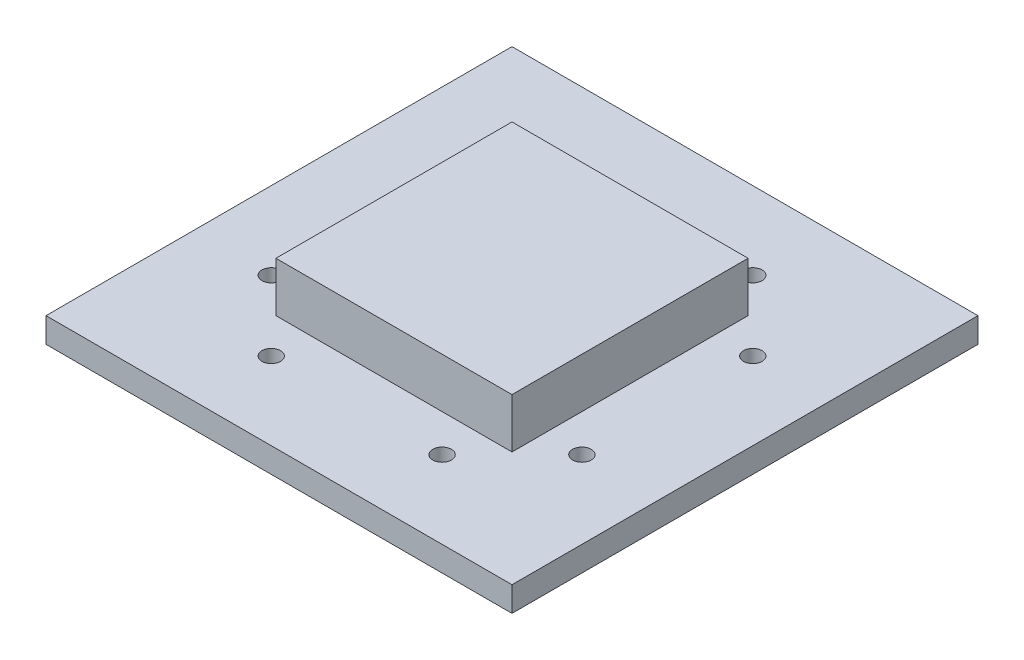
from build123d import *

# Parameters (mm, degrees)
SKETCH1_W           = 30
SKETCH1_H           = 30
BOSS_EXTRUDE1_DEPTH = 1.6
SKETCH2_R           = 0.6
CUT_EXTRUDE1_DEPTH  = 1.6
CIRPATTERN1_COUNT   = 2
CIRPATTERN1_ANGLE   = 90
SKETCH4_W           = 15.2
SKETCH4_H           = 15.2
BOSS_EXTRUDE2_DEPTH = 3.2


with BuildPart() as part:
    # Sketch1 → Boss-Extrude1 (new body)
    with BuildSketch(Plane(origin=(0, 0, 0), x_dir=(1, 0, 0), z_dir=(0, 1, 0))):
        with Locations((15, 15)):
            Rectangle(SKETCH1_W, SKETCH1_H)
    extrude(amount=BOSS_EXTRUDE1_DEPTH)

    # Sketch2 → Cut-Extrude1 (cut)
    with BuildSketch(Plane(origin=(0, 1.6, 0), x_dir=(1, 0, 0), z_dir=(0, 1, 0))):
        with Locations((20.5, 5)):
            Circle(SKETCH2_R)
        with Locations((9.5, 5)):
            Circle(SKETCH2_R)
        with Locations((20.5, 25)):
            Circle(SKETCH2_R)
        with Locations((9.5, 25)):
            Circle(SKETCH2_R)
    cut_extrude1 = extrude(amount=-CUT_EXTRUDE1_DEPTH, mode=Mode.SUBTRACT)

    # CirPattern1: Cut-Extrude1 ×2 about axis
    cirpattern1_axis = Axis((15, 0, -15), (0, 1, 0))
    for i in range(1, CIRPATTERN1_COUNT):
        add(cut_extrude1.rotate(cirpattern1_axis, i * CIRPATTERN1_ANGLE / (CIRPATTERN1_COUNT - 1)), mode=Mode.SUBTRACT)

    # Sketch4 → Boss-Extrude2 (add)
    with BuildSketch(Plane(origin=(0, 1.6, 0), x_dir=(1, 0, 0), z_dir=(0, 1, 0))):
        with Locations((15, 15)):
            Rectangle(SKETCH4_W, SKETCH4_H)
    extrude(amount=BOSS_EXTRUDE2_DEPTH)


solid = part.part
